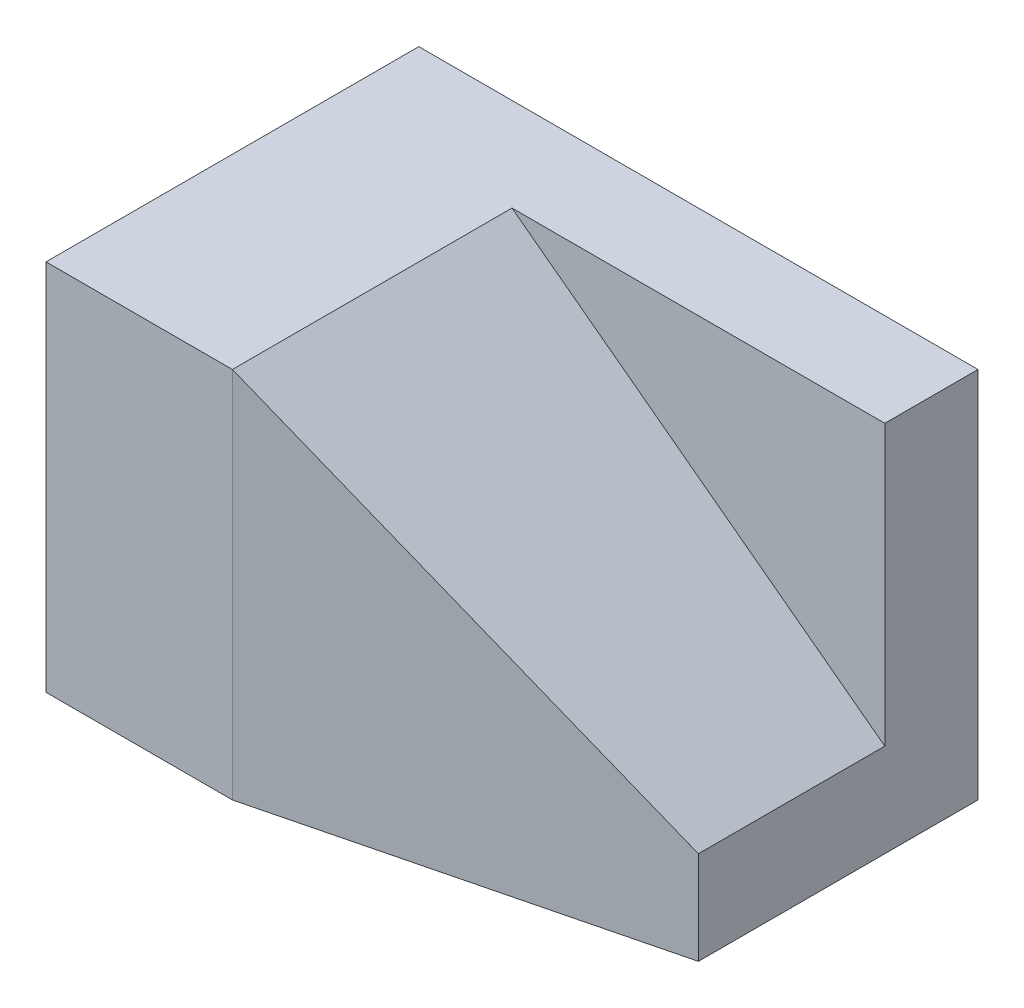
from build123d import *

# Parameters (mm, degrees)
EXTRUDE_1_DEPTH     = 20
EXTRUDE_2_DEPTH     = 20
CUT_EXTRUDE_1_DEPTH = 15


with BuildPart() as part:
    # 草圖1 → 填料-伸長1 (new body)
    with BuildSketch(Plane(origin=(0, 0, 0), x_dir=(1, 0, 0), z_dir=(0, 1, 0))):
        Polygon((-5, 5), (-5, -10), (15, -5), (15, 5), align=None)
    extrude(amount=EXTRUDE_1_DEPTH)

    # 草圖1<3> → 填料-伸長2 (add)
    with BuildSketch(Plane(origin=(0, 0, 0), x_dir=(1, 0, 0), z_dir=(0, 1, 0))):
        Polygon((-15, -10), (-5, -10), (-5, 5), (15, 5), (15, 10), (-15, 10), align=None)
    extrude(amount=EXTRUDE_2_DEPTH)

    # 草圖2 → 除料-伸長1 (cut)
    with BuildSketch(Plane.XY.offset(10)):
        Polygon((-5, 20), (15, 5), (15, 20), align=None)
    extrude(amount=-CUT_EXTRUDE_1_DEPTH, mode=Mode.SUBTRACT)


solid = part.part
